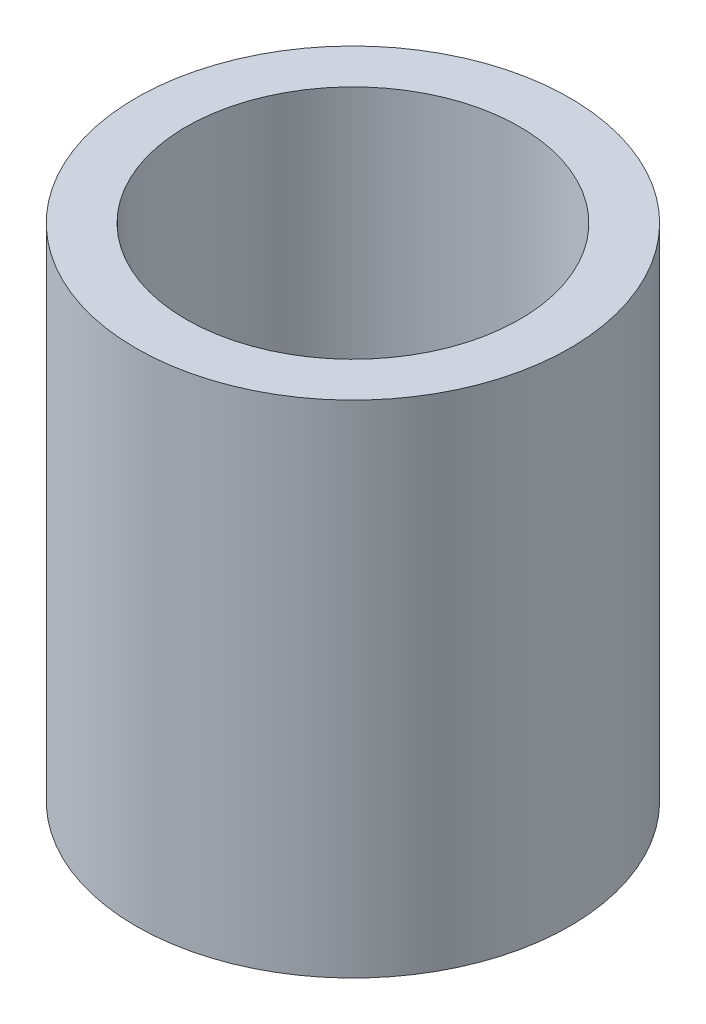
from build123d import *

# Parameters (mm, degrees)
SKETCH1_R           = 2.6
SKETCH1_R_2         = 2
BOSS_EXTRUDE1_DEPTH = 6


with BuildPart() as part:
    # Sketch1 → Boss-Extrude1 (new body)
    with BuildSketch(Plane(origin=(0, 0, 0), x_dir=(1, 0, 0), z_dir=(0, 1, 0))):
        Circle(SKETCH1_R)
        Circle(SKETCH1_R_2, mode=Mode.SUBTRACT)
    extrude(amount=BOSS_EXTRUDE1_DEPTH)


solid = part.part
